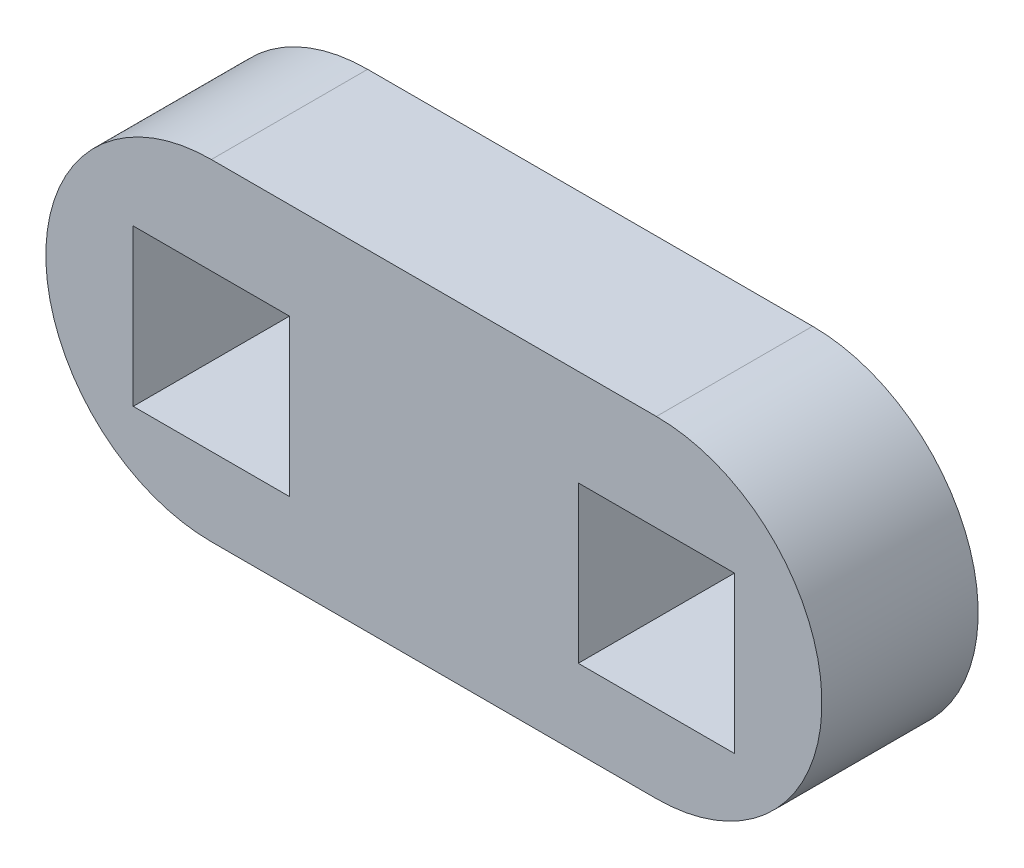
from build123d import *

# Parameters (mm, degrees)
SKETCH1_W           = 5.9944
SKETCH1_H           = 5.9944
BOSS_EXTRUDE1_DEPTH = 5.9944


with BuildPart() as part:
    # Sketch1 → Boss-Extrude1 (new body)
    with BuildSketch(Plane.XY):
        with BuildLine():
            Line((384.610540851, 111.993994152), (367.537765391, 111.993994152))
            ThreePointArc((367.537765391, 111.993994152), (361.187765391, 118.343994152), (367.537765391, 124.693994152))
            Line((367.537765391, 124.693994152), (384.610540851, 124.693994152))
            ThreePointArc((384.610540851, 124.693994152), (390.960540851, 118.343994152), (384.610540851, 111.993994152))
        make_face()
        with Locations((384.610540851, 117.991248441)):
            Rectangle(SKETCH1_W, SKETCH1_H, mode=Mode.SUBTRACT)
        with Locations((367.537765391, 117.991248441)):
            Rectangle(SKETCH1_W, SKETCH1_H, mode=Mode.SUBTRACT)
    extrude(amount=BOSS_EXTRUDE1_DEPTH)


solid = part.part
